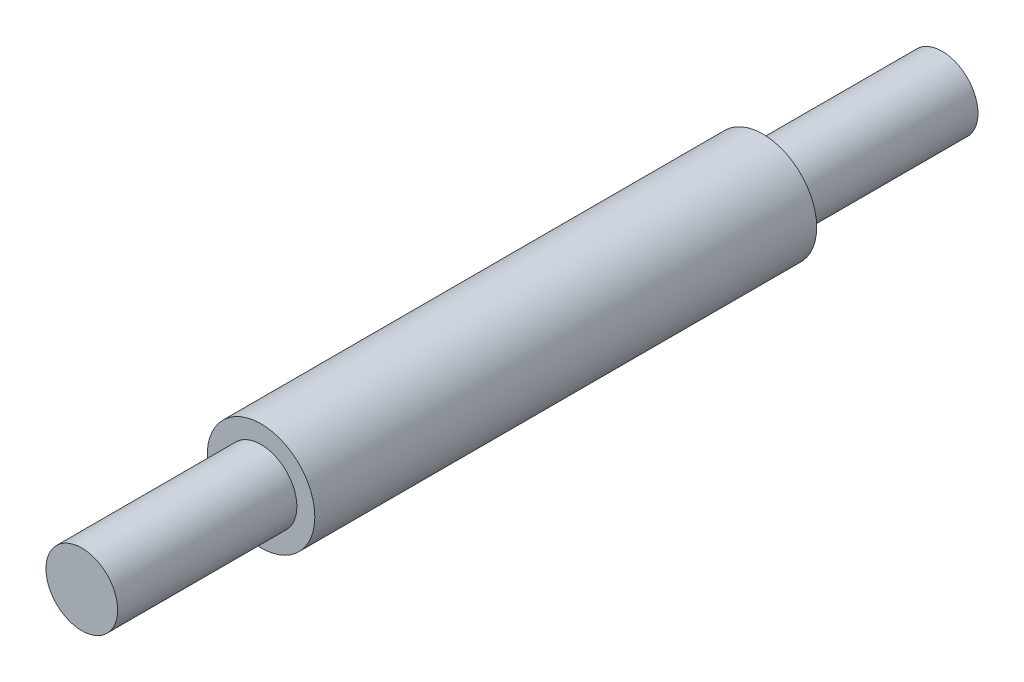
from build123d import *

# Parameters (mm, degrees)
SKETCH1_R           = 19.05
BOSS_EXTRUDE1_DEPTH = 177.8
SKETCH2_R           = 12.7
BOSS_EXTRUDE2_DEPTH = 63.5
SKETCH3_R           = 12.7
BOSS_EXTRUDE3_DEPTH = 63.5


with BuildPart() as part:
    # Sketch1 → Boss-Extrude1 (new body)
    with BuildSketch(Plane.XY):
        Circle(SKETCH1_R)
    extrude(amount=BOSS_EXTRUDE1_DEPTH)

    # Sketch2 → Boss-Extrude2 (add)
    with BuildSketch(Plane.XY.offset(177.8)):
        Circle(SKETCH2_R)
    extrude(amount=BOSS_EXTRUDE2_DEPTH)

    # Sketch3 → Boss-Extrude3 (add)
    with BuildSketch(Plane(origin=(0, 0, 0), x_dir=(-1, 0, 0), z_dir=(0, 0, -1))):
        Circle(SKETCH3_R)
    extrude(amount=BOSS_EXTRUDE3_DEPTH)


solid = part.part
